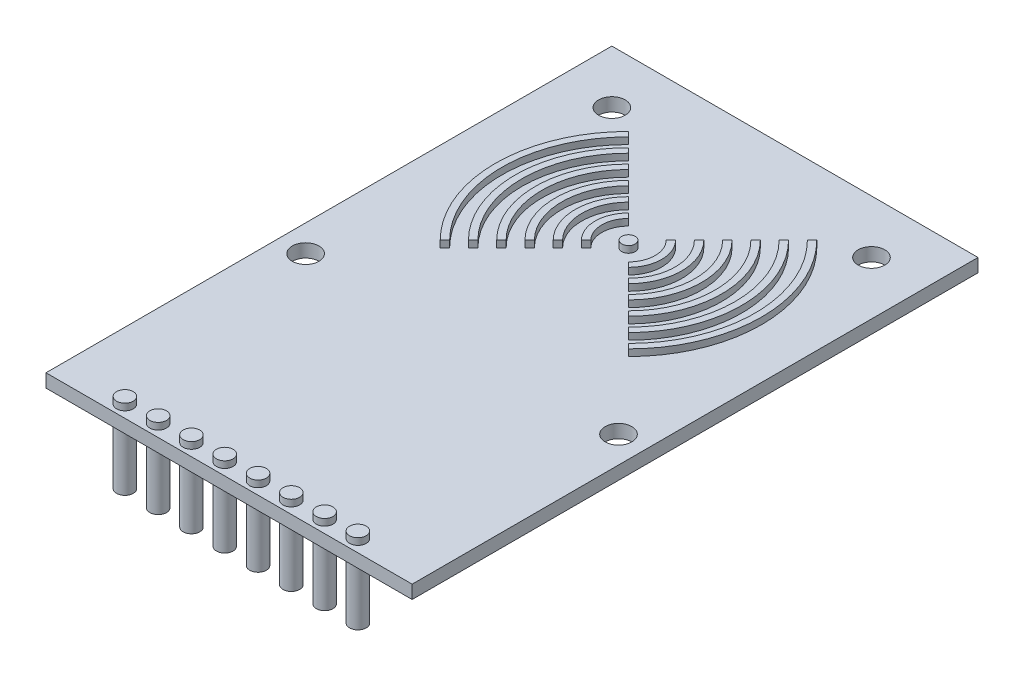
from build123d import *

# Parameters (mm, degrees)
ESBO_O1_W                     = 55
ESBO_O1_H                     = 85
RESSALTO_EXTRUS_O1_DEPTH      = 2
ESBO_O2_R                     = 1
RESSALTO_EXTRUS_O2_DEPTH      = 1
ESBO_O3_R                     = 1.25
RESSALTO_EXTRUS_O3_DEPTH      = 1
RESSALTO_EXTRUS_O3_DEPTH_BACK = 11
ESBO_O4_R                     = 2
CORTE_EXTRUS_O1_DEPTH         = 3


with BuildPart() as part:
    # Esboço1 → Ressalto-extrusão1 (new body)
    with BuildSketch(Plane(origin=(0, 0, 0), x_dir=(1, 0, 0), z_dir=(0, 1, 0))):
        with Locations((-52.185193749, -10.243624719)):
            Rectangle(ESBO_O1_W, ESBO_O1_H)
    extrude(amount=RESSALTO_EXTRUS_O1_DEPTH)

    # Esboço2 → Ressalto-extrusão2 (add)
    with BuildSketch(Plane(origin=(0, 2, 0), x_dir=(1, 0, 0), z_dir=(0, 1, 0))):
        with Locations((-52.185193749, 7.256375281)):
            Circle(ESBO_O2_R)
        with BuildLine():
            Line((-55.720727655, 10.791909187), (-55.013620874, 10.084802406))
            ThreePointArc((-55.013620874, 10.084802406), (-56.185193749, 7.256375281), (-55.013620874, 4.427948156))
            Line((-55.013620874, 4.427948156), (-55.720727655, 3.720841375))
            ThreePointArc((-55.720727655, 3.720841375), (-57.185193749, 7.256375281), (-55.720727655, 10.791909187))
        make_face()
        with BuildLine():
            Line((-57.842047999, 12.91322953), (-57.134941218, 12.206122749))
            ThreePointArc((-57.134941218, 12.206122749), (-59.185193749, 7.256375281), (-57.134941218, 2.306627813))
            Line((-57.134941218, 2.306627813), (-57.842047999, 1.599521031))
            ThreePointArc((-57.842047999, 1.599521031), (-60.185193749, 7.256375281), (-57.842047999, 12.91322953))
        make_face()
        with BuildLine():
            Line((-59.963368343, 15.034549874), (-59.256261561, 14.327443093))
            ThreePointArc((-59.256261561, 14.327443093), (-62.185193749, 7.256375281), (-59.256261561, 0.185307469))
            Line((-59.256261561, 0.185307469), (-59.963368343, -0.521799312))
            ThreePointArc((-59.963368343, -0.521799312), (-63.185193749, 7.256375281), (-59.963368343, 15.034549874))
        make_face()
        with BuildLine():
            Line((-62.084688686, 17.155870218), (-61.377581905, 16.448763436))
            ThreePointArc((-61.377581905, 16.448763436), (-65.185193749, 7.256375281), (-61.377581905, -1.936012875))
            Line((-61.377581905, -1.936012875), (-62.084688686, -2.643119656))
            ThreePointArc((-62.084688686, -2.643119656), (-66.185193749, 7.256375281), (-62.084688686, 17.155870218))
        make_face()
        with BuildLine():
            Line((-64.20600903, 19.277190561), (-63.498902248, 18.57008378))
            ThreePointArc((-63.498902248, 18.57008378), (-68.185193749, 7.256375281), (-63.498902248, -4.057333218))
            Line((-63.498902248, -4.057333218), (-64.20600903, -4.764439999))
            ThreePointArc((-64.20600903, -4.764439999), (-69.185193749, 7.256375281), (-64.20600903, 19.277190561))
        make_face()
        with BuildLine():
            Line((-66.327329373, 21.398510905), (-65.620222592, 20.691404123))
            ThreePointArc((-65.620222592, 20.691404123), (-71.185193749, 7.256375281), (-65.620222592, -6.178653562))
            Line((-65.620222592, -6.178653562), (-66.327329373, -6.885760343))
            ThreePointArc((-66.327329373, -6.885760343), (-72.185193749, 7.256375281), (-66.327329373, 21.398510905))
        make_face()
        with BuildLine():
            ThreePointArc((-49.356766625, 4.427948156), (-48.185193749, 7.256375281), (-49.356766625, 10.084802406))
            Line((-49.356766625, 10.084802406), (-48.649659844, 10.791909187))
            ThreePointArc((-48.649659844, 10.791909187), (-47.185193749, 7.256375281), (-48.649659844, 3.720841375))
            Line((-48.649659844, 3.720841375), (-49.356766625, 4.427948156))
        make_face()
        with BuildLine():
            ThreePointArc((-47.235446281, 2.306627813), (-45.185193749, 7.256375281), (-47.235446281, 12.206122749))
            Line((-47.235446281, 12.206122749), (-46.5283395, 12.91322953))
            ThreePointArc((-46.5283395, 12.91322953), (-44.185193749, 7.256375281), (-46.5283395, 1.599521031))
            Line((-46.5283395, 1.599521031), (-47.235446281, 2.306627813))
        make_face()
        with BuildLine():
            ThreePointArc((-45.114125938, 0.185307469), (-42.185193749, 7.256375281), (-45.114125938, 14.327443093))
            Line((-45.114125938, 14.327443093), (-44.407019156, 15.034549874))
            ThreePointArc((-44.407019156, 15.034549874), (-41.185193749, 7.256375281), (-44.407019156, -0.521799312))
            Line((-44.407019156, -0.521799312), (-45.114125938, 0.185307469))
        make_face()
        with BuildLine():
            ThreePointArc((-42.992805594, -1.936012875), (-39.185193749, 7.256375281), (-42.992805594, 16.448763436))
            Line((-42.992805594, 16.448763436), (-42.285698813, 17.155870218))
            ThreePointArc((-42.285698813, 17.155870218), (-38.185193749, 7.256375281), (-42.285698813, -2.643119656))
            Line((-42.285698813, -2.643119656), (-42.992805594, -1.936012875))
        make_face()
        with BuildLine():
            ThreePointArc((-40.87148525, -4.057333218), (-36.185193749, 7.256375281), (-40.87148525, 18.57008378))
            Line((-40.87148525, 18.57008378), (-40.164378469, 19.277190561))
            ThreePointArc((-40.164378469, 19.277190561), (-35.185193749, 7.256375281), (-40.164378469, -4.764439999))
            Line((-40.164378469, -4.764439999), (-40.87148525, -4.057333218))
        make_face()
        with BuildLine():
            ThreePointArc((-38.750164907, -6.178653562), (-33.185193749, 7.256375281), (-38.750164907, 20.691404123))
            Line((-38.750164907, 20.691404123), (-38.043058126, 21.398510905))
            ThreePointArc((-38.043058126, 21.398510905), (-32.185193749, 7.256375281), (-38.043058126, -6.885760343))
            Line((-38.043058126, -6.885760343), (-38.750164907, -6.178653562))
        make_face()
    extrude(amount=RESSALTO_EXTRUS_O2_DEPTH)

    # Esboço3 → Ressalto-extrusão3 (add, two sides)
    with BuildSketch(Plane(origin=(0, 2, 0), x_dir=(1, 0, 0), z_dir=(0, 1, 0))) as ressalto_extrus_o3_sk:
        with Locations((-69.685193749, -50.8911199)):
            Circle(ESBO_O3_R)
        with Locations((-64.685193749, -50.8911199)):
            Circle(ESBO_O3_R)
        with Locations((-59.685193749, -50.8911199)):
            Circle(ESBO_O3_R)
        with Locations((-54.685193749, -50.8911199)):
            Circle(ESBO_O3_R)
        with Locations((-49.685193749, -50.8911199)):
            Circle(ESBO_O3_R)
        with Locations((-44.685193749, -50.8911199)):
            Circle(ESBO_O3_R)
        with Locations((-39.685193749, -50.8911199)):
            Circle(ESBO_O3_R)
        with Locations((-34.685193749, -50.8911199)):
            Circle(ESBO_O3_R)
    extrude(amount=RESSALTO_EXTRUS_O3_DEPTH)
    extrude(ressalto_extrus_o3_sk.sketch, amount=-RESSALTO_EXTRUS_O3_DEPTH_BACK)

    # Esboço4 → Corte-extrusão1 (cut)
    with BuildSketch(Plane(origin=(0, 2, 0), x_dir=(1, 0, 0), z_dir=(0, 1, 0))):
        with Locations((-71.685193749, 24.256375281)):
            Circle(ESBO_O4_R)
        with Locations((-32.685193749, 24.256375281)):
            Circle(ESBO_O4_R)
        with Locations((-75.685193749, -17.743624719)):
            Circle(ESBO_O4_R)
        with Locations((-28.685193749, -17.743624719)):
            Circle(ESBO_O4_R)
    extrude(amount=-CORTE_EXTRUS_O1_DEPTH, mode=Mode.SUBTRACT)


solid = part.part
